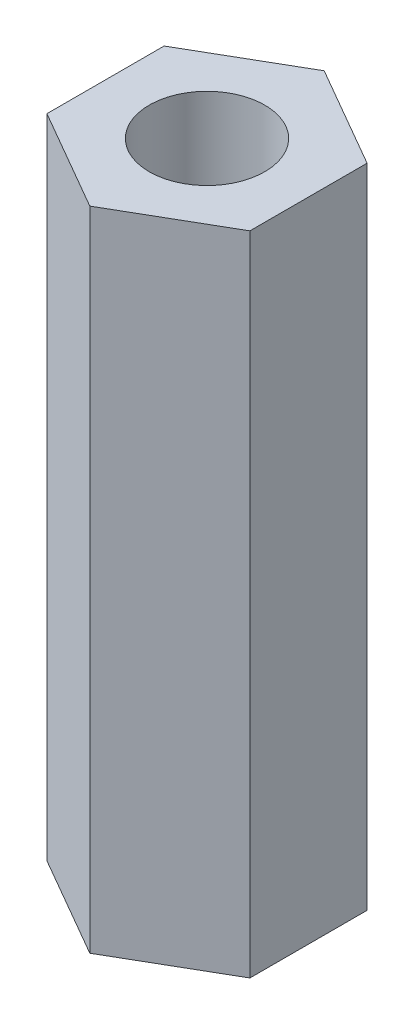
from build123d import *

# Parameters (mm, degrees)
SKETCH_1_R      = 1.5
EXTRUDE_1_DEPTH = 16.8


with BuildPart() as part:
    # Эскиз1 → Бобышка-Вытянуть1 (new body)
    with BuildSketch(Plane(origin=(0, 0, 0), x_dir=(1, 0, 0), z_dir=(0, 1, 0))):
        Polygon((0, 3.042635919), (-2.635, 1.521317959), (-2.635, -1.521317959), (0, -3.042635919), (2.635, -1.521317959), (2.635, 1.521317959), align=None)
        Circle(SKETCH_1_R, mode=Mode.SUBTRACT)
    extrude(amount=EXTRUDE_1_DEPTH)


solid = part.part
